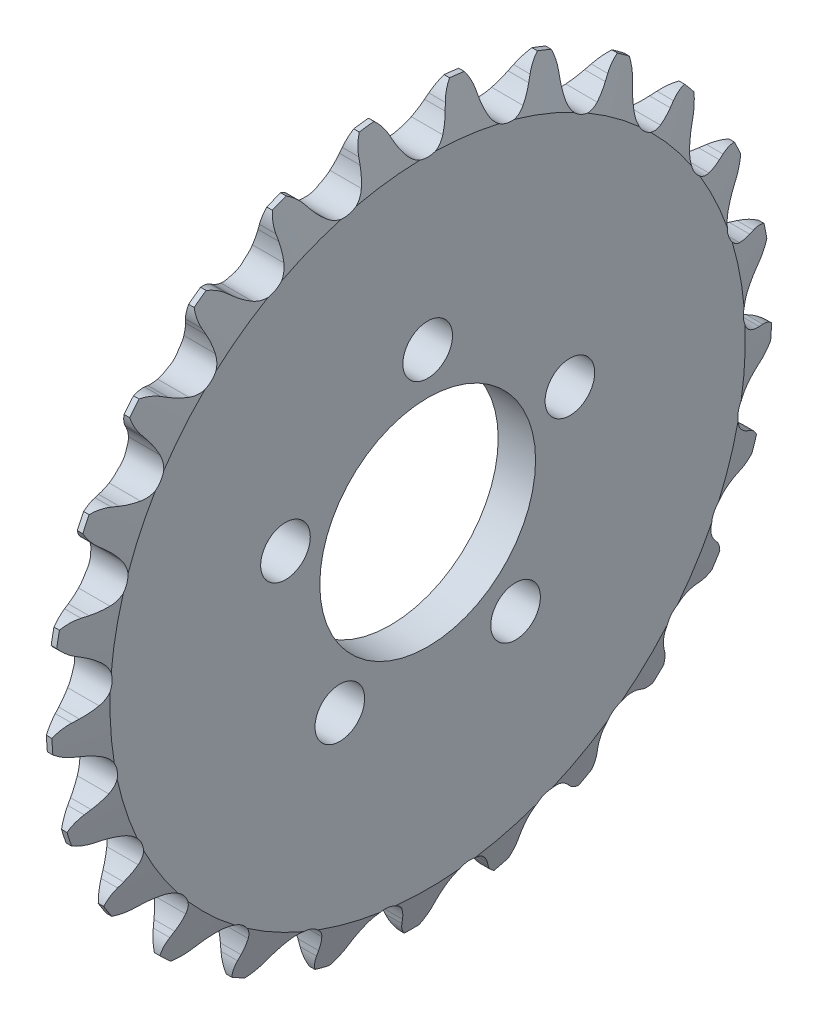
from build123d import *

# Parameters (mm, degrees)
CUT_EXTRUDE1_DEPTH = 39.096205228
CIRPATTERN1_COUNT  = 25
SKETCH4_R          = 8.0645
SKETCH4_R_2        = 1.8542
CUT_EXTRUDE2_DEPTH = 39.156046097


with BuildPart() as part:
    # Sketch2 → Revolve1 (revolve)
    with BuildSketch(Plane.XY):
        Polygon((-0.206375, 26.919966974), (0.206375, 26.919966974), (1.397, 23.744966974), (1.397, 0), (-1.397, 0), (-1.397, 23.744966974), align=None)
    revolve(axis=Axis((-1.397, 0, 0), (1, 0, 0)))

    # Sketch3 → Cut-Extrude1 (cut, symmetric)
    with BuildSketch(Plane(origin=(0, 0, 0), x_dir=(0, 0, -1), z_dir=(1, 0, 0))):
        with BuildLine():
            Line((-2.095139452, 25.741428061), (-1.934616579, 25.336819069))
            ThreePointArc((-1.934616579, 25.336819069), (-1.677162492, 24.79898923), (-1.348403628, 24.301534555))
            ThreePointArc((-1.348403628, 24.301534555), (0, 23.635111974), (1.348403628, 24.301534555))
            ThreePointArc((1.348403628, 24.301534555), (1.677162492, 24.79898923), (1.934616579, 25.336819069))
            Line((1.934616579, 25.336819069), (2.095139452, 25.741428061))
            ThreePointArc((2.095139452, 25.741428061), (2.628519051, 26.58334), (3.432640864, 27.172150344))
            ThreePointArc((3.432640864, 27.172150344), (0, 27.388113802), (-3.432640864, 27.172150344))
            ThreePointArc((-3.432640864, 27.172150344), (-2.628519051, 26.58334), (-2.095139452, 25.741428061))
        make_face()
    cut_extrude1 = extrude(amount=CUT_EXTRUDE1_DEPTH, both=True, mode=Mode.SUBTRACT)

    # CirPattern1: Cut-Extrude1 ×25 about axis
    cirpattern1_axis = Axis((-88.99, 0, 0), (1, 0, 0))
    for i in range(1, CIRPATTERN1_COUNT):
        add(cut_extrude1.rotate(cirpattern1_axis, i * 360 / CIRPATTERN1_COUNT), mode=Mode.SUBTRACT)

    # Sketch4 → Cut-Extrude2 (cut, through all)
    with BuildSketch(Plane(origin=(1.397, 0, 0), x_dir=(0, 0, -1), z_dir=(1, 0, 0))):
        Circle(SKETCH4_R)
        with Locations((0, 11.176)):
            Circle(SKETCH4_R_2)
        with Locations((10.629007626, 3.453573929)):
            Circle(SKETCH4_R_2)
        with Locations((6.56908798, -9.041573929)):
            Circle(SKETCH4_R_2)
        with Locations((-6.56908798, -9.041573929)):
            Circle(SKETCH4_R_2)
        with Locations((-10.629007626, 3.453573929)):
            Circle(SKETCH4_R_2)
    extrude(amount=-CUT_EXTRUDE2_DEPTH, mode=Mode.SUBTRACT)


solid = part.part
